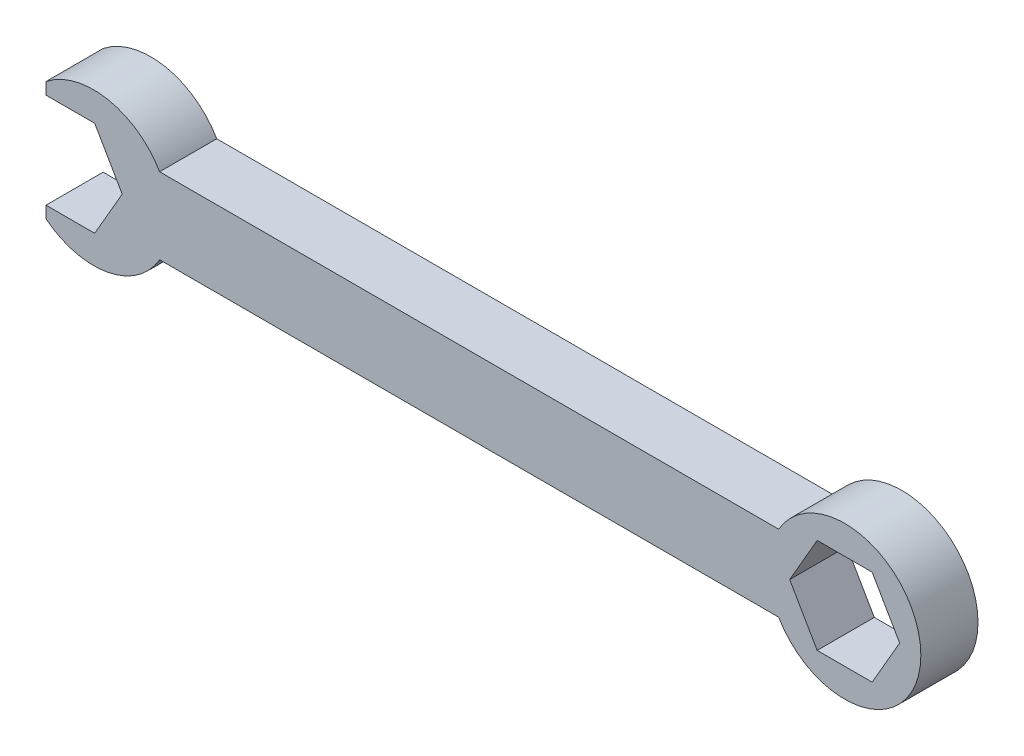
from build123d import *

# Parameters (mm, degrees)
BOSS_EXTRUDE1_DEPTH = 7.62


with BuildPart() as part:
    # Sketch1 → Boss-Extrude1 (new body)
    with BuildSketch(Plane.XY):
        with BuildLine():
            ThreePointArc((-8.798818102, -5.08), (10.16, 0), (-8.798818102, 5.08))
            Line((-8.798818102, 5.08), (-91.348818102, 5.08))
            ThreePointArc((-91.348818102, 5.08), (-98.268424141, 9.984696391), (-106.497636205, 7.931147458))
            Line((-106.497636205, 7.931147458), (-106.497636205, 6.35))
            Line((-106.497636205, 6.35), (-100.003810414, 6.35))
            Line((-100.003810414, 6.35), (-96.337636205, 0))
            Line((-96.337636205, 0), (-100.003810414, -6.35))
            Line((-100.003810414, -6.35), (-106.497636205, -6.35))
            Line((-106.497636205, -6.35), (-106.497636205, -7.931147458))
            ThreePointArc((-106.497636205, -7.931147458), (-98.268424141, -9.984696391), (-91.348818102, -5.08))
            Line((-91.348818102, -5.08), (-8.798818102, -5.08))
        make_face()
        Polygon((3.666174209, 6.35), (7.332348419, 0), (3.666174209, -6.35), (-3.666174209, -6.35), (-7.332348419, 0), (-3.666174209, 6.35), align=None, mode=Mode.SUBTRACT)
    extrude(amount=BOSS_EXTRUDE1_DEPTH)


solid = part.part
